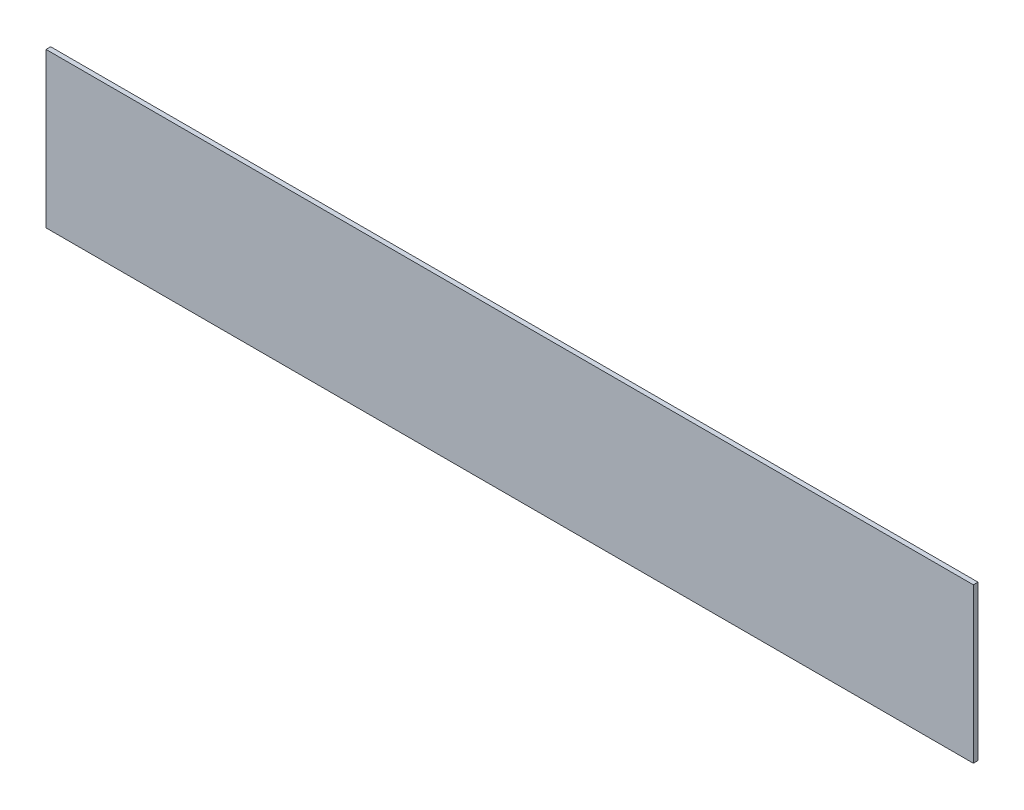
from build123d import *

# Parameters (mm, degrees)
SKETCH1_W           = 600
SKETCH1_H           = 100
BOSS_EXTRUDE1_DEPTH = 3


with BuildPart() as part:
    # Sketch1 → Boss-Extrude1 (new body)
    with BuildSketch(Plane.XY):
        with Locations((300, 50)):
            Rectangle(SKETCH1_W, SKETCH1_H)
    extrude(amount=BOSS_EXTRUDE1_DEPTH)


solid = part.part
